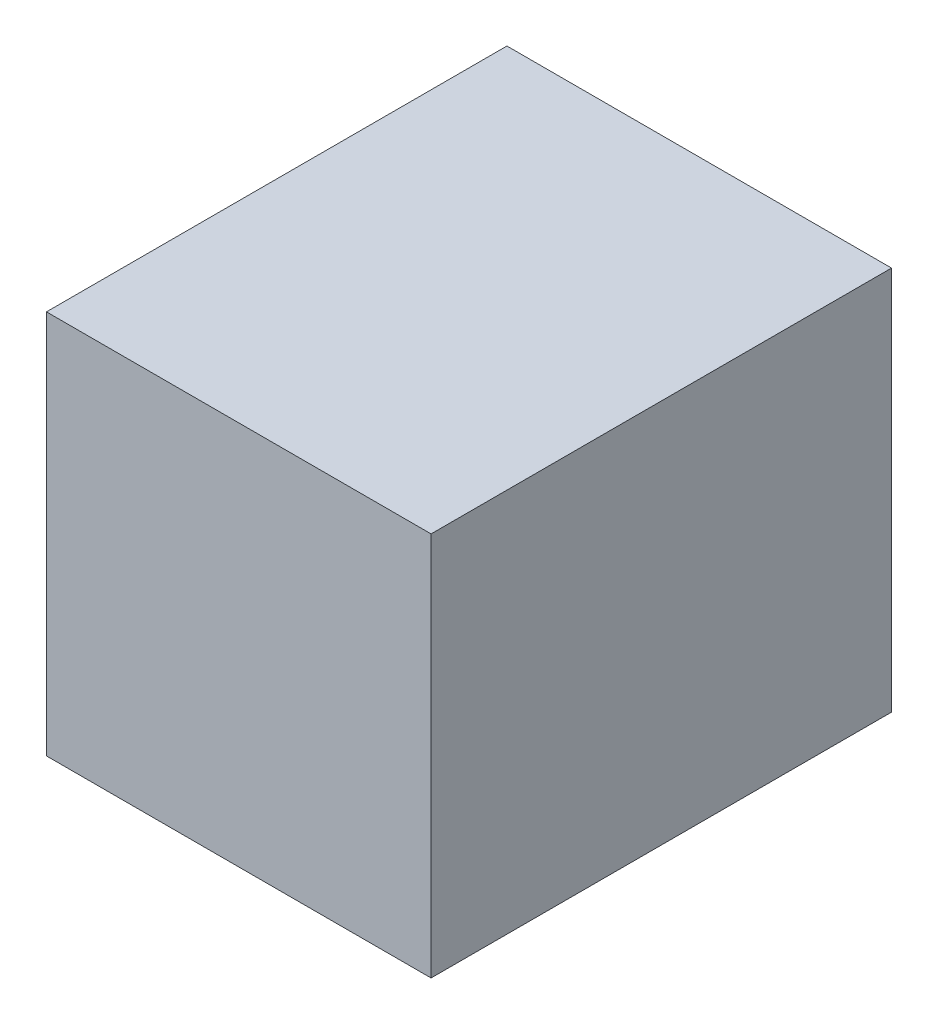
from build123d import *

# Parameters (mm, degrees)
SCHIZZO1_W                   = 133.643181644
SCHIZZO1_H                   = 133.643181644
ESTRUSIONE_ESTRUSIONE1_DEPTH = 160


with BuildPart() as part:
    # Schizzo1 → Estrusione-Estrusione1 (new body)
    with BuildSketch(Plane.XY):
        Rectangle(SCHIZZO1_W, SCHIZZO1_H)
    extrude(amount=ESTRUSIONE_ESTRUSIONE1_DEPTH)


solid = part.part
